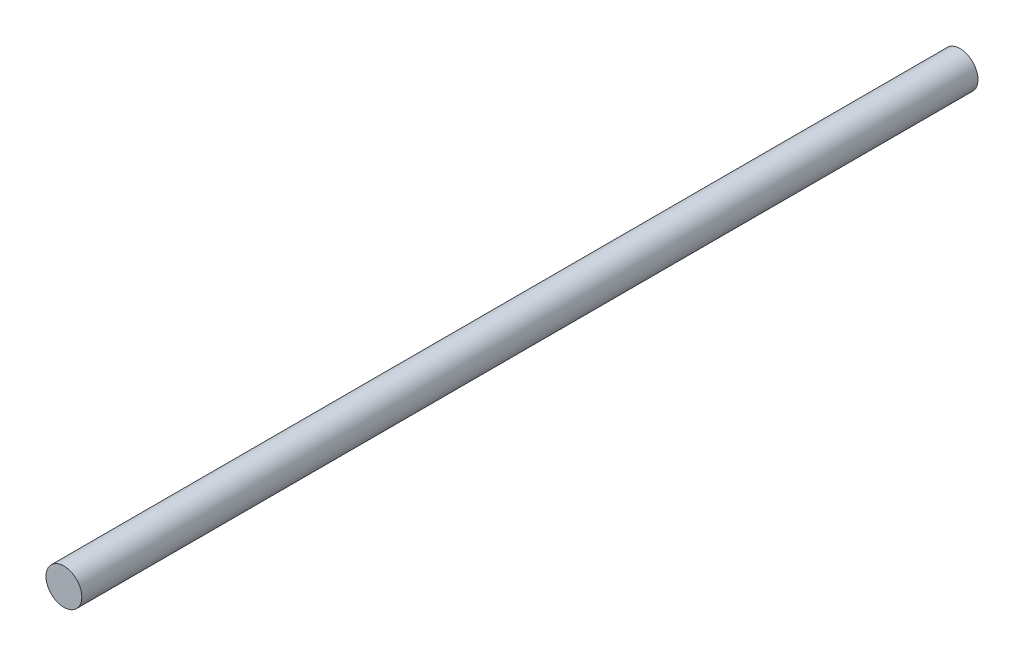
from build123d import *

# Parameters (mm, degrees)
SKETCH_1_R      = 4
EXTRUDE_1_DEPTH = 100


with BuildPart() as part:
    # 草图1 → 凸台-拉伸1 (new body, symmetric)
    with BuildSketch(Plane.XY):
        Circle(SKETCH_1_R)
    extrude(amount=EXTRUDE_1_DEPTH, both=True)


solid = part.part
